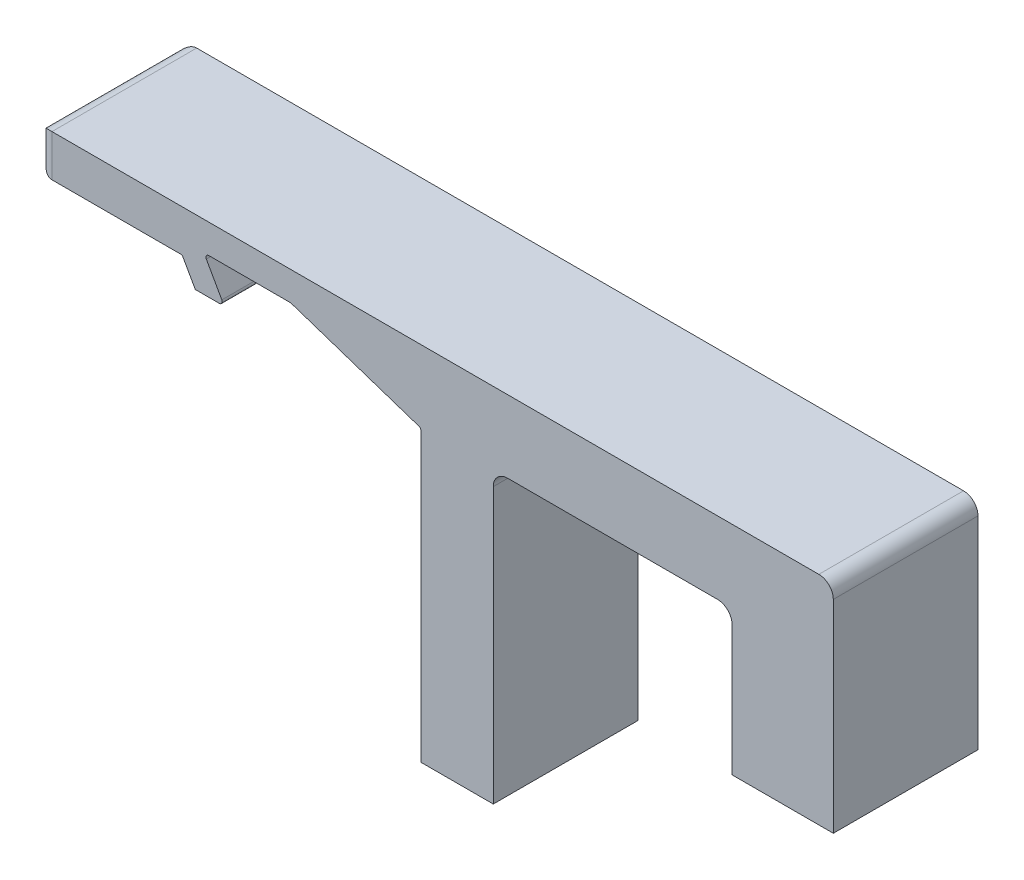
from build123d import *

# Parameters (mm, degrees)
BOSS_EXTRUDE1_DEPTH = 10
FILLET3_R           = 0.2
FILLET4_R           = 1


with BuildPart() as part:
    # Sketch1 → Boss-Extrude1 (new body)
    with BuildSketch(Plane.XY):
        Polygon((-48, 2.11152184), (-48, 5), (7, 5), (7, -10), (0, -10), (0, 0), (-16.5, 0), (-16.5, -20), (-21.5, -20), (-21.5, 0), (-30.5, 3), (-36.5, 3), (-35.093099913, 0.5), (-37.093099913, 0.5), (-38, 2.11152184), align=None)
    extrude(amount=BOSS_EXTRUDE1_DEPTH)

    # Fillet3
    fillet3_edges = [part.edges().sort_by_distance(p)[0] for p in [
        (-36.5, 3, 5),
        (-35.093099913, 0.5, 5),
        (-38, 2.11152184, 5),
        (-21.5, 0, 5),
        (-30.5, 3, 5),
    ]]
    fillet(fillet3_edges, radius=FILLET3_R)

    # Fillet4
    fillet4_edges = [part.edges().sort_by_distance(p)[0] for p in [
        (-48, 3.55576092, 0),
        (-48, 2.11152184, 5),
        (-48, 5, 5),
        (7, 5, 5),
        (0, 0, 5),
        (-16.5, 0, 5),
        (-48, 3.55576092, 10),
    ]]
    fillet(fillet4_edges, radius=FILLET4_R)


solid = part.part
